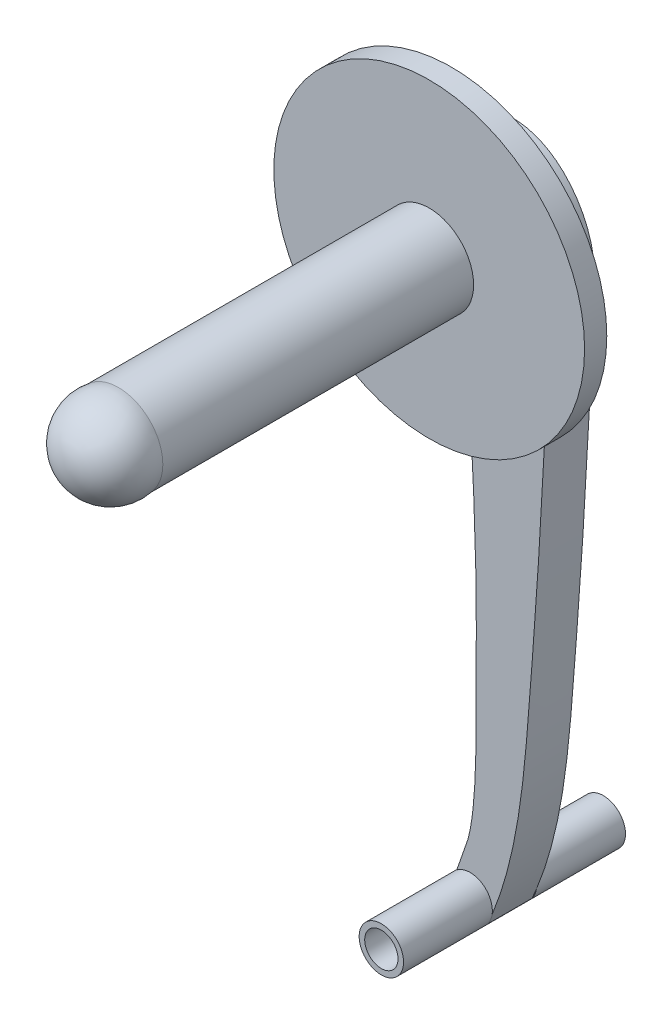
from build123d import *

# Parameters (mm, degrees)
ARM_EXTRUDE_DEPTH               = 6.35
SKETCH2_R                       = 9.525
ARM_HANDLE_SPACER_EXTRUDE_DEPTH = 3.175
SKETCH3_R                       = 22.225
HANDLE_BASE_EXTRUDE_DEPTH       = 3.175
SKETCH5_R                       = 6.35
HANDLE_EXTRUDE_DEPTH            = 44.45
HANDLE_DOME_FACE_RADIUS         = 6.35
HANDLE_DOME_HEIGHT              = 7.62
SKETCH7_R                       = 3.175
ARM_SLIDER_FRONT_EXTRUDE_DEPTH  = 12.7
SKETCH8_R                       = 2.38125
CUT_EXTRUDE2_DEPTH              = 32.75


with BuildPart() as part:
    # Sketch1 → Arm Extrude (new body)
    with BuildSketch(Plane.XY):
        with BuildLine():
            Line((-0.310063399, 7.13327902), (0, 8.488899908))
            add(Edge.make_bspline(
                [(-22.423405471, 80.151651473), (-23.098171501, 78.484949301), (-21.710179313, 73.657775145), (-19.982664596, 68.767759849), (-12.453425552, 67.167681912), (-8.244325833, 69.309188007), (0.045366857, 67.680494517), (0.404487115, 52.749214724), (0.963776807, 37.596157832), (0.846768385, 32.342612133), (0.858192704, 19.921164935), (0.823670064, 12.744528573), (0, 8.488899908)],
                knots=[0, 0, 0, 0, 0.058727348, 0.134625817, 0.156810162, 0.266819613, 0.304169719, 0.492961109, 0.537826005, 0.707953781, 0.747032645, 0.907348672, 0.907348672, 0.907348672, 0.907348672], degree=3))
            ThreePointArc((-22.423405471, 80.151651473), (-13.001351905, 89.7825331), (0, 93.317193334))
            add(Edge.make_bspline(
                [(0, 93.317193334), (5.09918481, 93.206839261), (12.41398629, 85.562110082), (10.911801572, 68.491523269), (10.094953114, 49.982890958), (8.238650167, 25.055582438), (6.791847576, 7.644498002), (2.506632281, -1.9486969)],
                knots=[0, 0, 0, 0, 0.141745524, 0.264046814, 0.488239671, 0.695067487, 1, 1, 1, 1], degree=3))
            ThreePointArc((2.506632281, -1.9486969), (-2.26156039, -2.228445558), (-1.911512943, 2.535102221))
            add(Edge.make_bspline(
                [(-1.911512943, 2.535102221), (-1.082346176, 4.824407889), (-0.310063399, 7.13327902)],
                knots=[0, 0, 0, 1, 1, 1], degree=2))
        make_face()
    extrude(amount=ARM_EXTRUDE_DEPTH)

    # Sketch2 → Arm-Handle Spacer Extrude (add)
    with BuildSketch(Plane.XY.offset(6.35)):
        with Locations((0.494989456, 82.55)):
            Circle(SKETCH2_R)
    extrude(amount=ARM_HANDLE_SPACER_EXTRUDE_DEPTH)

    # Sketch3 → Handle Base Extrude (add)
    with BuildSketch(Plane.XY.offset(9.525)):
        with Locations((0.494989456, 82.55)):
            Circle(SKETCH3_R)
    extrude(amount=HANDLE_BASE_EXTRUDE_DEPTH)

    # Sketch5 → Handle Extrude (add)
    with BuildSketch(Plane.XY.offset(12.7)):
        with Locations((0.494989456, 82.55)):
            Circle(SKETCH5_R)
    extrude(amount=HANDLE_EXTRUDE_DEPTH)

    # Handle Dome: a dome of height H over a round flat face of radius A is a cap of a sphere of radius (A * A + H * H) / (2 * H)
    handle_dome_r = (HANDLE_DOME_FACE_RADIUS * HANDLE_DOME_FACE_RADIUS + HANDLE_DOME_HEIGHT * HANDLE_DOME_HEIGHT) / (2 * HANDLE_DOME_HEIGHT)
    handle_dome_base = Plane((0.494989456, 82.55, 57.15), z_dir=(0, 0, 1))
    with Locations(handle_dome_base.offset(HANDLE_DOME_HEIGHT - handle_dome_r)):
        handle_dome_ball = Sphere(handle_dome_r, mode=Mode.PRIVATE)
    add(split(handle_dome_ball, bisect_by=handle_dome_base, keep=Keep.TOP, mode=Mode.PRIVATE))

    # Sketch7 → Arm Slider Front Extrude (add)
    with BuildSketch(Plane.XY.offset(6.35)):
        Circle(SKETCH7_R)
    arm_slider_front_extrude = extrude(amount=ARM_SLIDER_FRONT_EXTRUDE_DEPTH)

    # Arm Slider Back Mirror: Arm Slider Front Extrude across plane
    add(arm_slider_front_extrude.mirror(Plane.XY.offset(3.175)))

    # Sketch8 → Cut-Extrude2 (cut, through all)
    with BuildSketch(Plane.XY.offset(19.05)):
        Circle(SKETCH8_R)
    extrude(amount=-CUT_EXTRUDE2_DEPTH, mode=Mode.SUBTRACT)


solid = part.part
